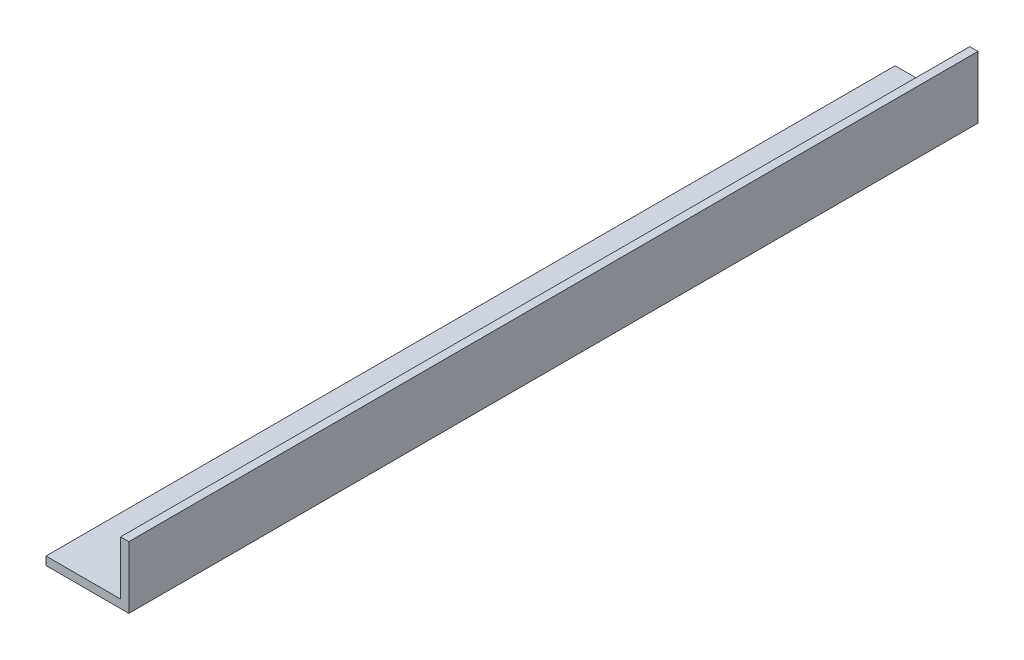
from build123d import *

# Parameters (mm, degrees)
AUFSATZ_LINEAR_AUSTRAGEN1_DEPTH = 205


with BuildPart() as part:
    # Skizze1 → Aufsatz-Linear austragen1 (new body)
    with BuildSketch(Plane.XY):
        Polygon((0, 0), (20, 0), (20, 15), (18, 15), (18, 2), (0, 2), align=None)
    extrude(amount=AUFSATZ_LINEAR_AUSTRAGEN1_DEPTH)


solid = part.part
